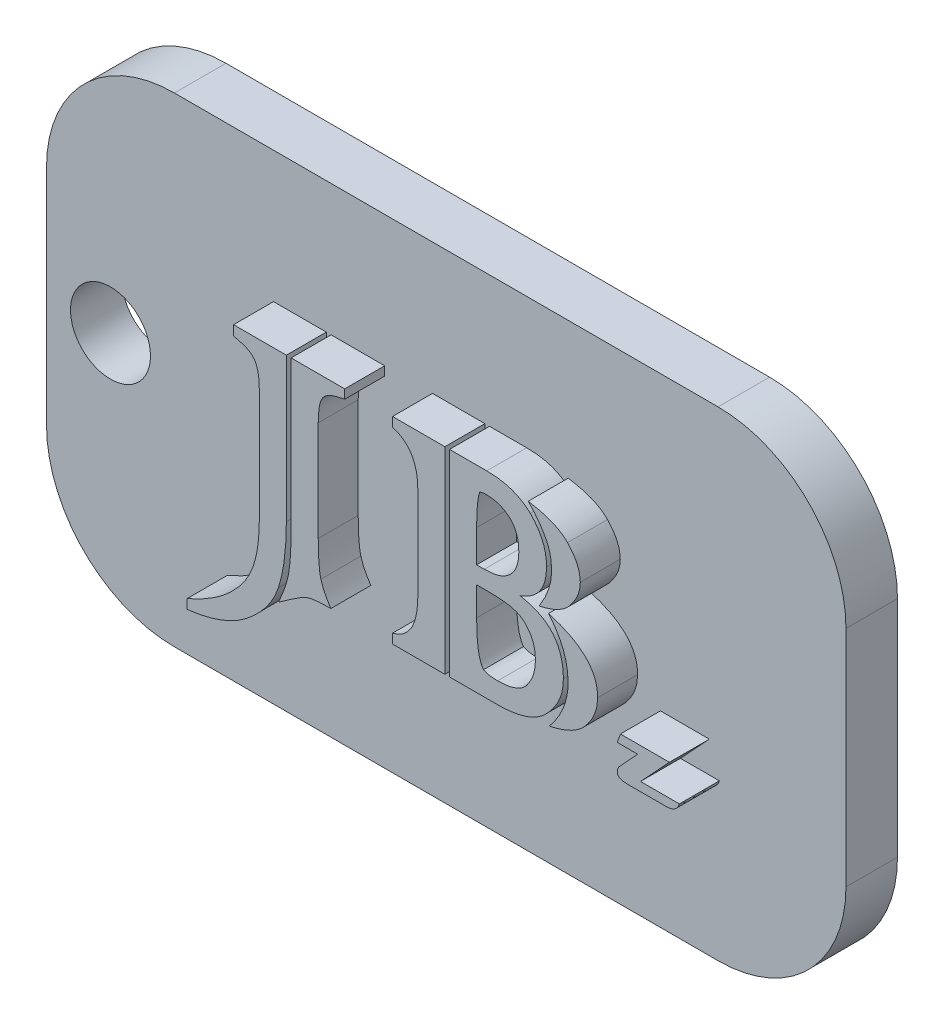
from build123d import *

# Parameters (mm, degrees)
SKETCH1_W            = 50
SKETCH1_H            = 30
BOSS_EXTRUDE2_DEPTH  = 3.220647484
FILLET4_R            = 8
SKETCH8_R            = 2.5
CUT_EXTRUDE3_DEPTH   = 30.332108179
BOSS_EXTRUDE15_DEPTH = 2.5
BOSS_EXTRUDE16_DEPTH = 2.5


with BuildPart() as part:
    # Sketch1 → Boss-Extrude2 (new body)
    with BuildSketch(Plane.XY):
        Rectangle(SKETCH1_W, SKETCH1_H)
    extrude(amount=BOSS_EXTRUDE2_DEPTH)

    # Fillet4
    fillet4_edges = [part.edges().sort_by_distance(p)[0] for p in [
        (-25, 15, 1.610323742),
        (25, 15, 1.610323742),
        (25, -15, 1.610323742),
        (-25, -15, 1.610323742),
    ]]
    fillet(fillet4_edges, radius=FILLET4_R)

    # Sketch8 → Cut-Extrude3 (cut, through all)
    with BuildSketch(Plane.XY.offset(3.220647484)):
        with Locations((-21, 0)):
            Circle(SKETCH8_R)
    extrude(amount=-CUT_EXTRUDE3_DEPTH, mode=Mode.SUBTRACT)

    # Sketch4 → Boss-Extrude15 (add)
    with BuildSketch(Plane.XY.offset(3.220647484)):
        with BuildLine():
            Line((-7.500726111, 6.79960548), (-7.500726111, -2.219924217))
            add(Edge.make_bspline(
                [(-7.500726111, -2.219924217), (-7.501742816, -2.40806561), (-7.50373447, -2.776621721), (-7.527567752, -3.317669543), (-7.568564406, -3.833717743), (-7.621520232, -4.326544149), (-7.692257324, -4.793175672), (-7.776986956, -5.236396541), (-7.875759019, -5.654545935), (-7.959890863, -5.921896656), (-8.000872381, -6.052126044)],
                knots=[0, 0, 0, 0, 1.163626577, 2.279464808, 3.348739122, 4.365132985, 5.34458117, 6.26692964, 7.155802935, 8, 8, 8, 8], degree=3))
            add(Edge.make_bspline(
                [(-8.000872381, -6.052126044), (-8.044039677, -6.172278901), (-8.131010231, -6.414354771), (-8.297374351, -6.766693028), (-8.499314849, -7.108349397), (-8.729043325, -7.44604349), (-8.998188345, -7.771728855), (-9.295044804, -8.094390705), (-9.627792626, -8.405093779), (-9.866325075, -8.601442058), (-9.987939995, -8.70154953)],
                knots=[0, 0, 0, 0, 0.91168771, 1.836806904, 2.77805918, 3.744530915, 4.751203907, 5.793244959, 6.874893795, 8, 8, 8, 8], degree=3))
            add(Edge.make_bspline(
                [(-9.987939995, -8.70154953), (-10.108091326, -8.791624385), (-10.350434691, -8.973303967), (-10.746976193, -9.208579244), (-11.168012706, -9.422783417), (-11.622436263, -9.604703374), (-12.104296236, -9.763160993), (-12.616876701, -9.894568159), (-13.157403142, -9.999944536), (-13.529185116, -10.046469467), (-13.718760822, -10.07019304)],
                knots=[0, 0, 0, 0, 0.89466599, 1.804527394, 2.744570503, 3.7085605, 4.719434449, 5.766770036, 6.861251546, 8, 8, 8, 8], degree=3))
            Line((-13.718760822, -10.07019304), (-13.718760822, -9.499080069))
            add(Edge.make_bspline(
                [(-13.718760822, -9.499080069), (-13.443086306, -9.3711534), (-12.91194508, -9.124677489), (-12.175885179, -8.70633694), (-11.53014826, -8.258556136), (-11.155310655, -7.923509845), (-10.974715069, -7.76208559)],
                knots=[0, 0, 0, 0, 1.117225652, 2.152555163, 3.109906857, 4, 4, 4, 4], degree=3))
            add(Edge.make_bspline(
                [(-10.974715069, -7.76208559), (-10.817522756, -7.604523983), (-10.510260003, -7.296539374), (-10.126019649, -6.784639982), (-9.804860487, -6.255024307), (-9.656178981, -5.877719857), (-9.582415993, -5.690533808)],
                knots=[0, 0, 0, 0, 1.05932704, 2.070659419, 3.042826981, 4, 4, 4, 4], degree=3))
            add(Edge.make_bspline(
                [(-9.582415993, -5.690533808), (-9.549686469, -5.592895448), (-9.482561444, -5.392648803), (-9.402077917, -5.076377008), (-9.336566822, -4.738645105), (-9.276451755, -4.380763153), (-9.24048616, -4.001110868), (-9.202736441, -3.602748901), (-9.188655662, -3.182012219), (-9.185348911, -2.89467033), (-9.183650723, -2.747105421)],
                knots=[0, 0, 0, 0, 0.828079208, 1.698308759, 2.622298841, 3.59498135, 4.615561753, 5.688529311, 6.812940348, 8, 8, 8, 8], degree=3))
            Line((-9.183650723, -2.747105421), (-9.183650723, 3.96093746))
            add(Edge.make_bspline(
                [(-9.183650723, 3.96093746), (-9.1875034, 4.134626647), (-9.194630392, 4.455930909), (-9.245679731, 4.896656061), (-9.33178891, 5.261128777), (-9.436849407, 5.459451455), (-9.484414359, 5.549239805)],
                knots=[0, 0, 0, 0, 1.274570017, 2.357802374, 3.2565136, 4, 4, 4, 4], degree=3))
            add(Edge.make_bspline(
                [(-9.484414359, 5.549239805), (-9.546421989, 5.621753286), (-9.681207619, 5.779375423), (-9.98116682, 5.950442778), (-10.360916661, 6.089450534), (-10.646969328, 6.15327013), (-10.802367368, 6.187940109)],
                knots=[0, 0, 0, 0, 0.760363031, 1.652796757, 2.724882428, 4, 4, 4, 4], degree=3))
            Line((-10.802367368, 6.187940109), (-10.802367368, 6.79960548))
            add(Edge.make_bspline(
                [(-10.802367368, 6.79960548), (-10.484706899, 6.79960548), (-9.87754735, 6.79960548), (-9.009050111, 6.79960548), (-8.226163494, 6.79960548), (-7.732775957, 6.79960548), (-7.500726111, 6.79960548)],
                knots=[0, 0, 0, 0, 1.154554759, 2.206755374, 3.156601842, 4, 4, 4, 4], degree=3))
        make_face()
        with BuildLine():
            Line((-3.851010085, 6.79960548), (-3.851010085, 6.23863061))
            add(Edge.make_bspline(
                [(-3.851010085, 6.23863061), (-3.936863495, 6.224025365), (-4.101665307, 6.195989546), (-4.334651226, 6.137188287), (-4.545673347, 6.074943582), (-4.7315891, 5.999931383), (-4.89575143, 5.919766973), (-5.035758732, 5.8295379), (-5.149483457, 5.726412264), (-5.2104222, 5.650301784), (-5.239929795, 5.613447772)],
                knots=[0, 0, 0, 0, 1.339176193, 2.570645267, 3.69437228, 4.720897219, 5.650878195, 6.501597605, 7.274447607, 8, 8, 8, 8], degree=3))
            add(Edge.make_bspline(
                [(-5.239929795, 5.613447772), (-5.28307915, 5.533771326), (-5.380086876, 5.35464395), (-5.448553627, 5.015624052), (-5.500216262, 4.601427017), (-5.504548443, 4.29579149), (-5.506899764, 4.129905795)],
                knots=[0, 0, 0, 0, 0.710068556, 1.596365353, 2.695411463, 4, 4, 4, 4], degree=3))
            Line((-5.506899764, 4.129905795), (-5.506899764, -2.132060683))
            add(Edge.make_bspline(
                [(-5.506899764, -2.132060683), (-5.505946935, -2.257096613), (-5.504126984, -2.49592166), (-5.498790901, -2.838483803), (-5.484154995, -3.149357971), (-5.468677542, -3.430063885), (-5.44578009, -3.680447456), (-5.414637397, -3.899987849), (-5.383047213, -4.088787253), (-5.354342274, -4.202623534), (-5.341310796, -4.254302965)],
                knots=[0, 0, 0, 0, 1.406466837, 2.686423893, 3.853198102, 4.906744294, 5.848536378, 6.679966792, 7.400730898, 8, 8, 8, 8], degree=3))
            add(Edge.make_bspline(
                [(-5.341310796, -4.254302965), (-5.309311978, -4.357446809), (-5.243504366, -4.569568712), (-5.106239145, -4.885759339), (-4.928618508, -5.207777583), (-4.78866042, -5.418907408), (-4.716127958, -5.528324207)],
                knots=[0, 0, 0, 0, 0.908527487, 1.868444799, 2.895333962, 4, 4, 4, 4], degree=3))
            add(Edge.make_bspline(
                [(-4.716127958, -5.528324207), (-4.89763369, -5.530575033), (-5.229544476, -5.534691009), (-5.680817496, -5.571205969), (-6.043718316, -5.624564159), (-6.244392655, -5.701209268), (-6.331465236, -5.734465575)],
                knots=[0, 0, 0, 0, 1.328973512, 2.430229832, 3.318876839, 4, 4, 4, 4], degree=3))
            add(Edge.make_bspline(
                [(-6.331465236, -5.734465575), (-6.365256112, -5.752486263), (-6.444417053, -5.794702822), (-6.579912324, -5.866993867), (-6.739520198, -5.97064), (-6.932013289, -6.092955675), (-7.152876058, -6.240525459), (-7.402214804, -6.41445361), (-7.684942868, -6.606109608), (-7.88064153, -6.745591953), (-7.983975548, -6.819242283)],
                knots=[0, 0, 0, 0, 0.464674997, 1.088581115, 1.862181435, 2.772032407, 3.856120924, 5.084395405, 6.460484428, 8, 8, 8, 8], degree=3))
            add(Edge.make_bspline(
                [(-7.983975548, -6.819242283), (-7.913818181, -6.657619749), (-7.77850067, -6.345886853), (-7.605423523, -5.883765815), (-7.464033614, -5.446937838), (-7.397474448, -5.159351107), (-7.365551443, -5.021419204)],
                knots=[0, 0, 0, 0, 1.10995282, 2.14084508, 3.108314995, 4, 4, 4, 4], degree=3))
            add(Edge.make_bspline(
                [(-7.365551443, -5.021419204), (-7.352633946, -4.950539555), (-7.324633782, -4.796899755), (-7.291676347, -4.548879052), (-7.265668895, -4.264695803), (-7.241447095, -3.947062729), (-7.226173568, -3.593149455), (-7.21148672, -3.205683119), (-7.206151819, -2.783164127), (-7.204302183, -2.490272858), (-7.203341842, -2.338202051)],
                knots=[0, 0, 0, 0, 0.642359634, 1.392388487, 2.229922982, 3.186711546, 4.232517862, 5.388302668, 6.643991939, 8, 8, 8, 8], degree=3))
            Line((-7.203341842, -2.338202051), (-7.203341842, 6.79960548))
            add(Edge.make_bspline(
                [(-7.203341842, 6.79960548), (-7.096328564, 6.79960548), (-6.872163907, 6.79960548), (-6.522962682, 6.79960548), (-6.145600068, 6.79960548), (-5.741202521, 6.79960548), (-5.307517129, 6.79960548), (-4.846796803, 6.79960548), (-4.357915089, 6.79960548), (-4.023357786, 6.79960548), (-3.851010085, 6.79960548)],
                knots=[0, 0, 0, 0, 0.766129032, 1.60483871, 2.5, 3.467741935, 4.5, 5.60483871, 6.766129032, 8, 8, 8, 8], degree=3))
        make_face()
        with BuildLine():
            add(Edge.make_bspline(
                [(8.943948079, -5.065350971), (9.038771139, -4.951141973), (9.225084498, -4.726738101), (9.457325455, -4.365736459), (9.665665173, -4.006512009), (9.829642354, -3.637760938), (9.961305895, -3.2629666), (10.049317316, -2.881913481), (10.112526384, -2.495743679), (10.117474108, -2.235955223), (10.119967687, -2.10502575)],
                knots=[0, 0, 0, 0, 1.093783453, 2.14912351, 3.161059152, 4.153921393, 5.120791099, 6.086017499, 7.035381616, 8, 8, 8, 8], degree=3))
            add(Edge.make_bspline(
                [(10.119967687, -2.10502575), (10.115933087, -1.965137536), (10.107927478, -1.687565938), (10.047804047, -1.275913013), (9.954183557, -0.871439687), (9.817662969, -0.475953416), (9.644690543, -0.089143682), (9.43307252, 0.288401238), (9.183569077, 0.657376545), (8.991017466, 0.889513374), (8.893257579, 1.007370972)],
                knots=[0, 0, 0, 0, 0.981501619, 1.947533422, 2.914050384, 3.891627577, 4.879002417, 5.88419523, 6.925790147, 8, 8, 8, 8], degree=3))
            add(Edge.make_bspline(
                [(8.893257579, 1.007370972), (9.017399775, 0.969845836), (9.259188165, 0.896759146), (9.609246813, 0.776877037), (9.932361152, 0.639706309), (10.236081889, 0.500274004), (10.511418378, 0.342701139), (10.76827759, 0.183538906), (10.993333124, 0.003973087), (11.203172391, -0.175592885), (11.380733047, -0.373673428), (11.538512611, -0.576982099), (11.671994473, -0.791720568), (11.779085553, -1.017873305), (11.864587252, -1.253052197), (11.926879824, -1.498459255), (11.958920482, -1.754980023), (11.965274529, -1.929224922), (11.968481267, -2.017162216)],
                knots=[0, 0, 0, 0, 1.334042184, 2.598277783, 3.80330444, 4.943588695, 6.032993904, 7.064739263, 8.047433356, 8.991383863, 9.901740271, 10.777751, 11.636269162, 12.496583798, 13.346931397, 14.206855814, 15.095042398, 16, 16, 16, 16], degree=3))
            add(Edge.make_bspline(
                [(11.968481267, -2.017162216), (11.960012969, -2.186212998), (11.942970411, -2.526429843), (11.781605961, -3.023072936), (11.538144004, -3.509894784), (11.305303591, -3.799740805), (11.184468195, -3.950159963)],
                knots=[0, 0, 0, 0, 0.949738011, 1.911359798, 2.916074481, 4, 4, 4, 4], degree=3))
            add(Edge.make_bspline(
                [(11.184468195, -3.950159963), (11.123983716, -4.015891151), (11.000046038, -4.15057977), (10.782359789, -4.327070767), (10.540098474, -4.490471292), (10.272562755, -4.639497628), (9.978074127, -4.770335893), (9.656980289, -4.885268602), (9.310749823, -4.986905265), (9.068244653, -5.038768402), (8.943948079, -5.065350971)],
                knots=[0, 0, 0, 0, 0.840608633, 1.72247632, 2.632007284, 3.591669923, 4.603490553, 5.664325459, 6.802844723, 8, 8, 8, 8], degree=3))
        make_face()
        with BuildLine():
            add(Edge.make_bspline(
                [(8.305247774, 1.115510707), (8.424860952, 1.309633277), (8.65594977, 1.68467185), (8.896574114, 2.278252557), (9.059495271, 2.862937006), (9.077187917, 3.254750129), (9.08588148, 3.447273723)],
                knots=[0, 0, 0, 0, 1.095876196, 2.117197624, 3.074855179, 4, 4, 4, 4], degree=3))
            add(Edge.make_bspline(
                [(9.08588148, 3.447273723), (9.082338041, 3.595285004), (9.075414711, 3.884476073), (8.991647805, 4.304569141), (8.871309297, 4.704644262), (8.746083467, 4.95039588), (8.683736844, 5.072749101)],
                knots=[0, 0, 0, 0, 1.048024629, 2.047677455, 3.027990316, 4, 4, 4, 4], degree=3))
            add(Edge.make_bspline(
                [(8.683736844, 5.072749101), (8.612588504, 5.19462793), (8.469365044, 5.439973186), (8.214030178, 5.787119473), (7.939199392, 6.131208659), (7.733594639, 6.346022053), (7.629374436, 6.454910078)],
                knots=[0, 0, 0, 0, 0.97078619, 1.954217885, 2.96300147, 4, 4, 4, 4], degree=3))
            add(Edge.make_bspline(
                [(7.629374436, 6.454910078), (7.7704336, 6.430319002), (8.043675864, 6.382684228), (8.434322625, 6.292442851), (8.79181001, 6.186881827), (9.117325945, 6.070815646), (9.408761993, 5.935350934), (9.666948182, 5.786707378), (9.893615891, 5.625861575), (10.021130731, 5.501324162), (10.082794654, 5.441100071)],
                knots=[0, 0, 0, 0, 1.27328383, 2.466447043, 3.563234111, 4.586895288, 5.53708409, 6.416853171, 7.234418186, 8, 8, 8, 8], degree=3))
            add(Edge.make_bspline(
                [(10.082794654, 5.441100071), (10.205220013, 5.301929123), (10.43856168, 5.03667051), (10.691570829, 4.594076994), (10.852427419, 4.146432949), (10.873418954, 3.842762464), (10.883704559, 3.693967492)],
                knots=[0, 0, 0, 0, 1.128237106, 2.150410079, 3.093722658, 4, 4, 4, 4], degree=3))
            add(Edge.make_bspline(
                [(10.883704559, 3.693967492), (10.875783498, 3.560108786), (10.859539954, 3.285607712), (10.724781841, 2.878012796), (10.510952969, 2.470201821), (10.318862486, 2.215689203), (10.217969321, 2.08200958)],
                knots=[0, 0, 0, 0, 0.902207741, 1.850137369, 2.870811087, 4, 4, 4, 4], degree=3))
            add(Edge.make_bspline(
                [(10.217969321, 2.08200958), (10.167255691, 2.026825705), (10.063506533, 1.913931392), (9.883069229, 1.762177896), (9.678198487, 1.623809999), (9.45159143, 1.495060136), (9.199573493, 1.379429225), (8.92258301, 1.281053357), (8.623583369, 1.186890205), (8.413803793, 1.139851918), (8.305247774, 1.115510707)],
                knots=[0, 0, 0, 0, 0.824309065, 1.686358684, 2.587384065, 3.542412089, 4.55213265, 5.634738538, 6.776032565, 8, 8, 8, 8], degree=3))
        make_face()
        with BuildLine():
            Line((2.415011633, 6.79960548), (2.415011633, -5.528324207))
            add(Edge.make_bspline(
                [(2.415011633, -5.528324207), (2.157053309, -5.528324207), (1.63099856, -5.528324207), (0.826709288, -5.528324207), (-0.006867829, -5.528324207), (-0.572348522, -5.528324207), (-0.859594691, -5.528324207)],
                knots=[0, 0, 0, 0, 0.945304438, 1.927760578, 2.947368421, 4, 4, 4, 4], degree=3))
            Line((-0.859594691, -5.528324207), (-0.859594691, -4.936935036))
            add(Edge.make_bspline(
                [(-0.859594691, -4.936935036), (-0.733504753, -4.89948803), (-0.487381995, -4.826392898), (-0.158725988, -4.626793504), (0.117484828, -4.363068063), (0.342218845, -4.035876434), (0.514886889, -3.644823432), (0.636986784, -3.192640435), (0.711307979, -2.676324751), (0.718268993, -2.311439266), (0.721948921, -2.118543216)],
                knots=[0, 0, 0, 0, 0.896123785, 1.749199525, 2.598862809, 3.489577914, 4.444199973, 5.507199799, 6.682185694, 8, 8, 8, 8], degree=3))
            Line((0.721948921, -2.118543216), (0.721948921, 3.626380158))
            add(Edge.make_bspline(
                [(0.721948921, 3.626380158), (0.718158361, 3.795638607), (0.710939963, 4.117958983), (0.636616495, 4.576214073), (0.511939264, 4.9825169), (0.340916561, 5.340662813), (0.113138479, 5.643305617), (-0.161401108, 5.895416544), (-0.489582325, 6.092344352), (-0.733779152, 6.17550713), (-0.859594691, 6.218354409)],
                knots=[0, 0, 0, 0, 1.234333659, 2.350552599, 3.374917423, 4.327048276, 5.231242262, 6.121466515, 7.032138525, 8, 8, 8, 8], degree=3))
            Line((-0.859594691, 6.218354409), (-0.859594691, 6.79960548))
            add(Edge.make_bspline(
                [(-0.859594691, 6.79960548), (-0.601636367, 6.79960548), (-0.075581618, 6.79960548), (0.727581198, 6.79960548), (1.561158315, 6.79960548), (2.126639008, 6.79960548), (2.415011633, 6.79960548)],
                knots=[0, 0, 0, 0, 0.945304438, 1.927760578, 2.943240454, 4, 4, 4, 4], degree=3))
        make_face()
        with BuildLine():
            Line((2.705637168, -5.528324207), (2.705637168, 6.79960548))
            Line((2.705637168, 6.79960548), (5.034020818, 6.79960548))
            add(Edge.make_bspline(
                [(5.034020818, 6.79960548), (5.176059623, 6.797351124), (5.452976339, 6.792956066), (5.855637004, 6.74904442), (6.232660257, 6.673572376), (6.587579194, 6.575000493), (6.914640083, 6.436600074), (7.223277394, 6.279319596), (7.504590164, 6.086730576), (7.671538327, 5.935307567), (7.754411004, 5.86014154)],
                knots=[0, 0, 0, 0, 1.154476416, 2.250749832, 3.287050024, 4.278305202, 5.239186462, 6.169017539, 7.091104606, 8, 8, 8, 8], degree=3))
            add(Edge.make_bspline(
                [(7.754411004, 5.86014154), (7.836191548, 5.774975113), (7.996524301, 5.608004255), (8.202639521, 5.334641561), (8.380567938, 5.05276562), (8.527181901, 4.75781437), (8.638266837, 4.450270688), (8.716251542, 4.131877126), (8.76495163, 3.802480691), (8.77160232, 3.578111892), (8.774979744, 3.464170557)],
                knots=[0, 0, 0, 0, 1.057876282, 2.073992256, 3.063248474, 4.043439923, 5.021130347, 5.988752034, 6.978626794, 8, 8, 8, 8], degree=3))
            add(Edge.make_bspline(
                [(8.774979744, 3.464170557), (8.770056992, 3.320714219), (8.760597344, 3.045045969), (8.680837264, 2.649891158), (8.552919383, 2.291327085), (8.373079929, 1.967677463), (8.133249246, 1.686077088), (7.84417009, 1.442484611), (7.502723603, 1.235826129), (7.250329741, 1.134437214), (7.119090066, 1.08171704)],
                knots=[0, 0, 0, 0, 1.101947222, 2.117521391, 3.084491276, 4.018964545, 4.946995871, 5.911636453, 6.914093423, 8, 8, 8, 8], degree=3))
            add(Edge.make_bspline(
                [(7.119090066, 1.08171704), (7.228678703, 1.060644238), (7.44268994, 1.019492013), (7.750006968, 0.935015979), (8.035805807, 0.833385207), (8.300598731, 0.715284011), (8.544689221, 0.579499058), (8.770159832, 0.428720786), (8.968475639, 0.253929682), (9.151249637, 0.067553158), (9.309218261, -0.140035495), (9.449268343, -0.363121052), (9.563658663, -0.605447667), (9.658630958, -0.863302292), (9.732459795, -1.138218708), (9.787406247, -1.430646258), (9.816704884, -1.740571864), (9.820599062, -1.952898605), (9.822583419, -2.061093983)],
                knots=[0, 0, 0, 0, 1.166012053, 2.277057997, 3.327175893, 4.333689507, 5.303381015, 6.243829573, 7.161980085, 8.061216499, 8.96782131, 9.882568872, 10.809359046, 11.762907118, 12.751075995, 13.780935907, 14.869231088, 16, 16, 16, 16], degree=3))
            add(Edge.make_bspline(
                [(9.822583419, -2.061093983), (9.820307074, -2.1682649), (9.81580634, -2.380160628), (9.770213625, -2.692638721), (9.69642982, -2.9952167), (9.589263316, -3.28722405), (9.458467589, -3.572461046), (9.294624356, -3.847048807), (9.100920168, -4.112806667), (8.952231544, -4.278099388), (8.876360745, -4.362442699)],
                knots=[0, 0, 0, 0, 1.007347585, 1.991703116, 2.962973114, 3.931465735, 4.912623443, 5.910117887, 6.933603513, 8, 8, 8, 8], degree=3))
            add(Edge.make_bspline(
                [(8.876360745, -4.362442699), (8.789882066, -4.456314365), (8.616258518, -4.644780837), (8.306451638, -4.882730838), (7.959219525, -5.080409127), (7.578745292, -5.2489616), (7.158802555, -5.371361679), (6.704246904, -5.461486865), (6.212742867, -5.521359423), (5.872288282, -5.525951499), (5.696376689, -5.528324207)],
                knots=[0, 0, 0, 0, 0.87501547, 1.756771616, 2.668047258, 3.613467245, 4.606794769, 5.663912532, 6.792952459, 8, 8, 8, 8], degree=3))
            add(Edge.make_bspline(
                [(5.696376689, -5.528324207), (5.449682921, -5.528324207), (4.937145639, -5.528324207), (4.424608358, -5.528324207), (4.158764845, -5.528324207)],
                knots=[0, 0, 0, 0, 0.962637363, 2, 2, 2, 2], degree=3))
            add(Edge.make_bspline(
                [(4.158764845, -5.528324207), (3.907565254, -5.528324207), (3.423189362, -5.528324207), (2.93881347, -5.528324207), (2.705637168, -5.528324207)],
                knots=[0, 0, 0, 0, 1.037209302, 2, 2, 2, 2], degree=3))
        make_face()
        with BuildLine():
            Line((5.165816119, 0.311221434), (4.39869988, 0.311221434))
            Line((4.39869988, 0.311221434), (4.39869988, -1.479842912))
            add(Edge.make_bspline(
                [(4.39869988, -1.479842912), (4.399873428, -1.645456252), (4.40210974, -1.96104875), (4.421970564, -2.408547491), (4.454611482, -2.806754376), (4.501777408, -3.15518519), (4.557806795, -3.456361326), (4.638219813, -3.704741918), (4.719587628, -3.909697052), (4.798804714, -4.016669814), (4.834638183, -4.06505843)],
                knots=[0, 0, 0, 0, 1.495197401, 2.849245615, 4.043529006, 5.100719848, 6.024218651, 6.802641707, 7.458380714, 8, 8, 8, 8], degree=3))
            add(Edge.make_bspline(
                [(4.834638183, -4.06505843), (4.881176611, -4.090550163), (4.986389812, -4.148181391), (5.184556574, -4.198080655), (5.433020465, -4.226051781), (5.616286342, -4.229021187), (5.716652889, -4.230647398)],
                knots=[0, 0, 0, 0, 0.698865575, 1.579982133, 2.674664151, 4, 4, 4, 4], degree=3))
            add(Edge.make_bspline(
                [(5.716652889, -4.230647398), (5.820348251, -4.228712837), (6.021453807, -4.224960972), (6.311255262, -4.195961494), (6.577105234, -4.141728047), (6.817703537, -4.066869852), (7.037244927, -3.97698237), (7.231882184, -3.862189334), (7.39910894, -3.721264965), (7.494274204, -3.614518161), (7.541510902, -3.561532793)],
                knots=[0, 0, 0, 0, 1.237290861, 2.399587259, 3.469868296, 4.468992185, 5.402680364, 6.294806285, 7.15360167, 8, 8, 8, 8], degree=3))
            add(Edge.make_bspline(
                [(7.541510902, -3.561532793), (7.623426482, -3.441158995), (7.786135066, -3.202061007), (7.956323753, -2.799402524), (8.056294899, -2.366768787), (8.068968547, -2.068393571), (8.075450839, -1.915781215)],
                knots=[0, 0, 0, 0, 0.9906154, 1.967655364, 2.960500444, 4, 4, 4, 4], degree=3))
            add(Edge.make_bspline(
                [(8.075450839, -1.915781215), (8.072193497, -1.794891185), (8.065872163, -1.560286987), (7.998991629, -1.22422256), (7.897393041, -0.912920159), (7.790403573, -0.729200819), (7.73751417, -0.638380606)],
                knots=[0, 0, 0, 0, 1.081896066, 2.099572311, 3.060538498, 4, 4, 4, 4], degree=3))
            add(Edge.make_bspline(
                [(7.73751417, -0.638380606), (7.67899573, -0.554312878), (7.565335276, -0.391028006), (7.360194567, -0.181933617), (7.13140341, -0.015639689), (6.962886157, 0.060493202), (6.879155031, 0.098321333)],
                knots=[0, 0, 0, 0, 1.067697806, 2.073791029, 3.042925023, 4, 4, 4, 4], degree=3))
            add(Edge.make_bspline(
                [(6.879155031, 0.098321333), (6.772844514, 0.132800727), (6.539300336, 0.20854546), (6.141530828, 0.262729506), (5.677089147, 0.305692001), (5.343951981, 0.30929489), (5.165816119, 0.311221434)],
                knots=[0, 0, 0, 0, 0.772021683, 1.695986199, 2.767992511, 4, 4, 4, 4], degree=3))
        make_face(mode=Mode.SUBTRACT)
        with BuildLine():
            Line((4.39869988, 3.413480056), (4.39869988, 1.392618775))
            Line((4.39869988, 1.392618775), (4.87856995, 1.392618775))
            add(Edge.make_bspline(
                [(4.87856995, 1.392618775), (5.044673305, 1.398987745), (5.359591037, 1.411062767), (5.800865121, 1.503585635), (6.183755011, 1.663970073), (6.387803819, 1.829211328), (6.487148495, 1.909661879)],
                knots=[0, 0, 0, 0, 1.152332408, 2.184723527, 3.116201388, 4, 4, 4, 4], degree=3))
            add(Edge.make_bspline(
                [(6.487148495, 1.909661879), (6.572435485, 2.001688685), (6.746921275, 2.18996324), (6.913728296, 2.553521179), (7.0234229, 2.968771561), (7.032945256, 3.266196523), (7.037985265, 3.423618156)],
                knots=[0, 0, 0, 0, 0.904314609, 1.850106915, 2.86210062, 4, 4, 4, 4], degree=3))
            add(Edge.make_bspline(
                [(7.037985265, 3.423618156), (7.033001761, 3.58552208), (7.023532521, 3.893158401), (6.912692107, 4.320417361), (6.739438855, 4.693671514), (6.559213225, 4.884119427), (6.470251661, 4.978126834)],
                knots=[0, 0, 0, 0, 1.13822127, 2.162753034, 3.093112549, 4, 4, 4, 4], degree=3))
            add(Edge.make_bspline(
                [(6.470251661, 4.978126834), (6.367309048, 5.059418492), (6.162732303, 5.220968526), (5.803113274, 5.380085682), (5.417228262, 5.483824585), (5.148512593, 5.495781562), (5.010365251, 5.501928671)],
                knots=[0, 0, 0, 0, 0.990198578, 1.967810944, 2.955246943, 4, 4, 4, 4], degree=3))
            add(Edge.make_bspline(
                [(5.010365251, 5.501928671), (4.961756527, 5.502423681), (4.87431012, 5.503314196), (4.756527518, 5.482921889), (4.661394948, 5.465698636), (4.612276666, 5.436611313), (4.591323781, 5.424203237)],
                knots=[0, 0, 0, 0, 1.34716595, 2.423532474, 3.327510209, 4, 4, 4, 4], degree=3))
            add(Edge.make_bspline(
                [(4.591323781, 5.424203237), (4.57605071, 5.374812658), (4.542687911, 5.266922897), (4.503069081, 5.087387752), (4.470237546, 4.878557688), (4.443720715, 4.641745726), (4.423362579, 4.375741965), (4.41167376, 4.08040438), (4.400129861, 3.756007462), (4.399189016, 3.530644134), (4.39869988, 3.413480056)],
                knots=[0, 0, 0, 0, 0.611888304, 1.336620951, 2.174178303, 3.113819368, 4.157149651, 5.331984885, 6.612926365, 8, 8, 8, 8], degree=3))
        make_face(mode=Mode.SUBTRACT)
    extrude(amount=BOSS_EXTRUDE15_DEPTH)

    # Sketch10 → Boss-Extrude16 (add)
    with BuildSketch(Plane.XY.offset(3.220647484)):
        with BuildLine():
            add(Edge.make_bspline(
                [(17.081164598, -5.214271544), (17.066011721, -5.258289035), (17.036642758, -5.343602739), (16.969139282, -5.45826616), (16.88572444, -5.554825838), (16.78732956, -5.634901555), (16.672326659, -5.696064031), (16.541732187, -5.738903885), (16.396025138, -5.765192329), (16.293866747, -5.768078778), (16.240604217, -5.769583692)],
                knots=[0, 0, 0, 0, 1.022123322, 1.981056304, 2.905837961, 3.816315787, 4.755755888, 5.754243648, 6.829125423, 8, 8, 8, 8], degree=3))
            Line((16.240604217, -5.769583692), (13.875104618, -5.769583692))
            add(Edge.make_bspline(
                [(13.875104618, -5.769583692), (13.821909293, -5.768688718), (13.722104217, -5.767009568), (13.582949957, -5.751145838), (13.464443985, -5.725289844), (13.367337702, -5.687378501), (13.289060918, -5.640265713), (13.233737686, -5.578713675), (13.199576918, -5.505179793), (13.195890814, -5.452168998), (13.193979561, -5.424682788)],
                knots=[0, 0, 0, 0, 1.502888691, 2.819720008, 3.952424639, 4.920101633, 5.756279279, 6.508938348, 7.226881351, 8, 8, 8, 8], degree=3))
            add(Edge.make_bspline(
                [(13.193979561, -5.424682788), (13.196394654, -5.387543641), (13.201206989, -5.313539833), (13.23688286, -5.20555788), (13.295153485, -5.102967403), (13.349257145, -5.043390372), (13.377275954, -5.012537053)],
                knots=[0, 0, 0, 0, 0.962294696, 1.91747733, 2.921518332, 4, 4, 4, 4], degree=3))
            Line((13.377275954, -5.012537053), (14.475969716, -3.825991174))
            Line((14.475969716, -3.825991174), (13.193979561, -3.825991174))
            Line((13.193979561, -3.825991174), (13.393544864, -3.270679026))
            Line((13.393544864, -3.270679026), (16.456438431, -3.270679026))
            Line((16.456438431, -3.270679026), (14.648420168, -5.214271544))
            Line((14.648420168, -5.214271544), (17.081164598, -5.214271544))
        make_face()
    extrude(amount=BOSS_EXTRUDE16_DEPTH)


solid = part.part
